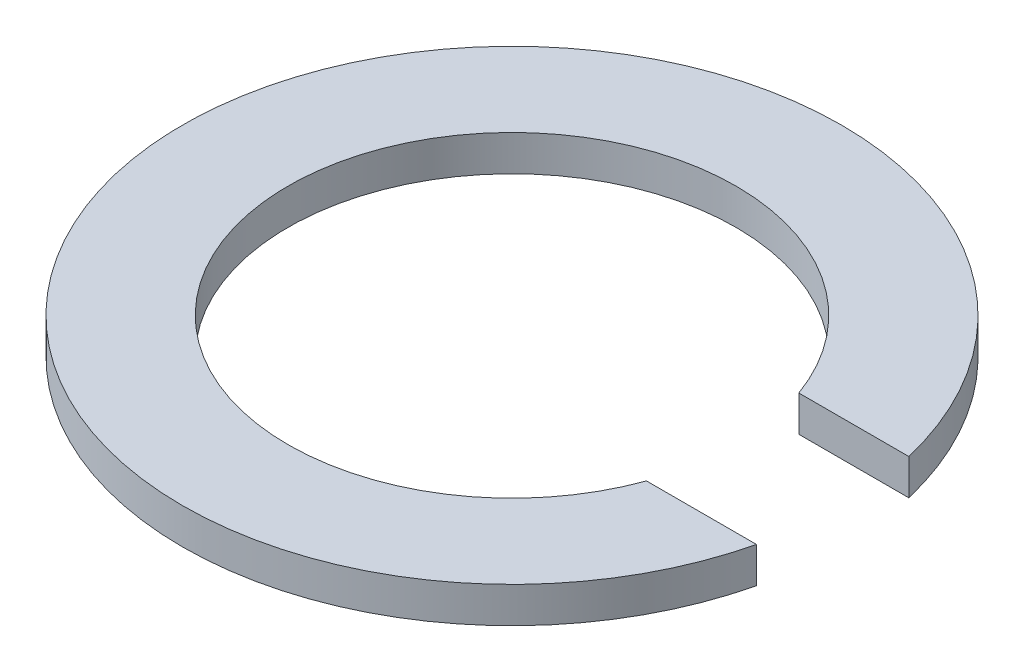
from build123d import *

# Parameters (mm, degrees)
BOSS_EXTRUDE2_DEPTH = 13.9


with BuildPart() as part:
    # Sketch1 → Boss-Extrude2 (new body)
    with BuildSketch(Plane(origin=(0, 0, 0), x_dir=(1, 0, 0), z_dir=(0, 1, 0))):
        with BuildLine():
            Line((81.816598446, -29.581146338), (124.534958069, -29.581146338))
            ThreePointArc((124.534958069, -29.581146338), (-128, -7.9131e-05), (124.534921494, 29.581300316))
            Line((124.534921494, 29.581300316), (81.816542775, 29.581300316))
            ThreePointArc((81.816542775, 29.581300316), (-87, -8.1866e-05), (81.816598446, -29.581146338))
        make_face()
    extrude(amount=BOSS_EXTRUDE2_DEPTH)


solid = part.part
